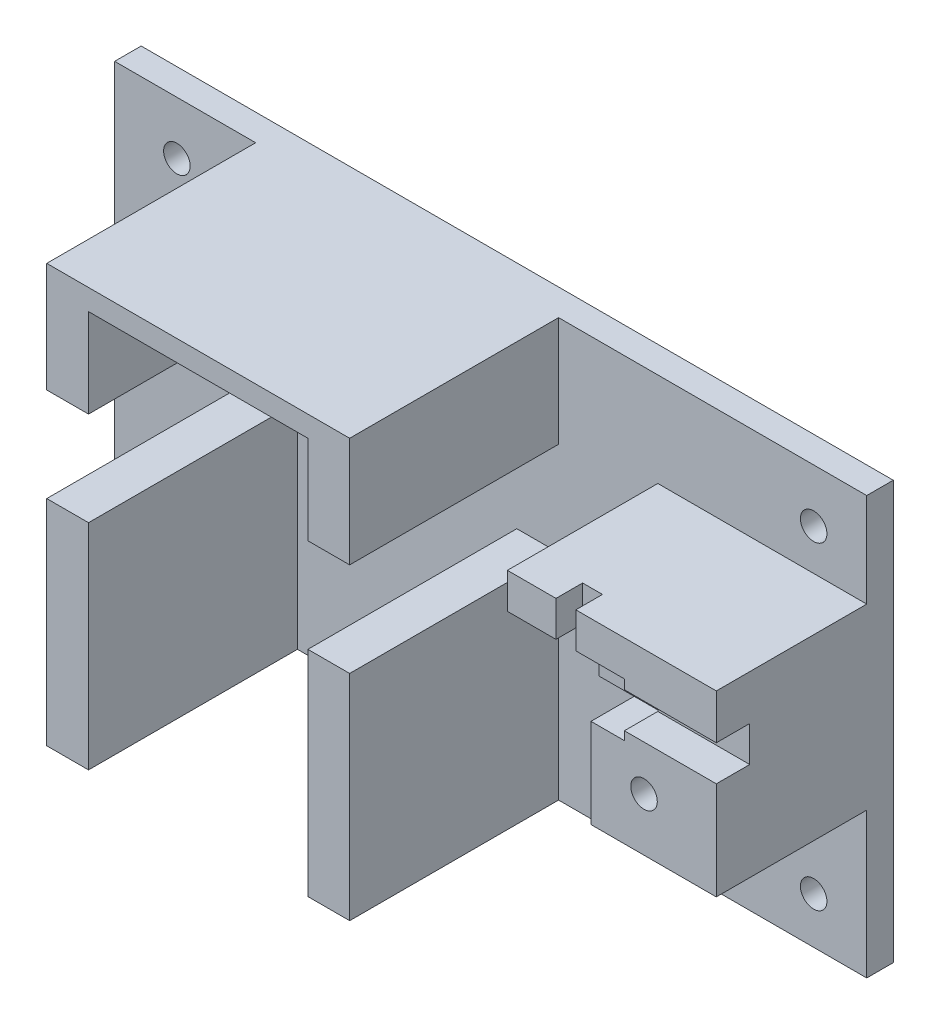
from build123d import *

# Parameters (mm, degrees)
SKETCH1_W            = 180
SKETCH1_H            = 100
BOSS_EXTRUDE1_DEPTH  = 6.35
SKETCH2_W            = 26.25
SKETCH2_H            = 5
BOSS_EXTRUDE3_DEPTH  = 50
SKETCH3_W            = 30
SKETCH3_H            = 30
BOSS_EXTRUDE4_DEPTH  = 25.65
BOSS_EXTRUDE5_DEPTH  = 10.35
SKETCH5_W            = 22
SKETCH5_H            = 8.5
BOSS_EXTRUDE6_DEPTH  = 2.35
SKETCH6_W            = 20
SKETCH6_H            = 8.5
BOSS_EXTRUDE7_DEPTH  = 29.625
SKETCH8_W            = 3.625
SKETCH8_H            = 8.5
SKETCH8_W_2          = 11.625
BOSS_EXTRUDE8_DEPTH  = 6.375
SKETCH9_W            = 8.375
SKETCH9_H            = 12.8
BOSS_EXTRUDE9_DEPTH  = 25.65
SKETCH10_R           = 3.175
CUT_EXTRUDE1_DEPTH   = 6.35
SKETCH11_W           = 30
SKETCH11_H           = 12.7
BOSS_EXTRUDE10_DEPTH = 36
SKETCH12_R           = 3.175
CUT_EXTRUDE2_DEPTH   = 10


with BuildPart() as part:
    # Sketch1 → Boss-Extrude1 (new body)
    with BuildSketch(Plane.XY):
        with Locations((90, 50)):
            Rectangle(SKETCH1_W, SKETCH1_H)
    extrude(amount=BOSS_EXTRUDE1_DEPTH)

    # Sketch2 → Boss-Extrude3 (add)
    with BuildSketch(Plane.XY.offset(6.35)):
        Polygon((43.75, 95), (43.75, 100), (33.75, 100), (33.75, 73.75), (43.75, 73.75), align=None)
        with Locations((56.875, 97.5)):
            Rectangle(SKETCH2_W, SKETCH2_H)
        with Locations((83.125, 97.5)):
            Rectangle(SKETCH2_W, SKETCH2_H)
        Polygon((106.25, 100), (96.25, 100), (96.25, 95), (96.25, 73.75), (106.25, 73.75), align=None)
        Polygon((33.75, 0), (43.75, 0), (43.75, 5), (43.75, 51.25), (33.75, 51.25), align=None)
        Polygon((96.25, 5), (96.25, 0), (106.25, 0), (106.25, 51.25), (96.25, 51.25), align=None)
    extrude(amount=BOSS_EXTRUDE3_DEPTH)

    # Sketch3 → Boss-Extrude4 (add)
    with BuildSketch(Plane.XY.offset(6.35)):
        with Locations((165, 62.5)):
            Rectangle(SKETCH3_W, SKETCH3_H)
    extrude(amount=BOSS_EXTRUDE4_DEPTH)

    # Sketch4 → Boss-Extrude5 (add)
    with BuildSketch(Plane.XY.offset(32)):
        Polygon((150, 77.5), (150, 69), (158, 69), (158, 66.75), (180, 66.75), (180, 77.5), align=None)
        Polygon((158, 56.2), (150, 56.2), (150, 47.5), (180, 47.5), (180, 58.25), (158, 58.25), align=None)
    extrude(amount=BOSS_EXTRUDE5_DEPTH)

    # Sketch5 → Boss-Extrude6 (add)
    with BuildSketch(Plane.XY.offset(32)):
        with Locations((169, 62.5)):
            Rectangle(SKETCH5_W, SKETCH5_H)
    extrude(amount=BOSS_EXTRUDE6_DEPTH)

    # Sketch6 → Boss-Extrude7 (add)
    with BuildSketch(Plane.XY.offset(6.35)):
        with Locations((140, 73.25)):
            Rectangle(SKETCH6_W, SKETCH6_H)
    extrude(amount=BOSS_EXTRUDE7_DEPTH)

    # Sketch8 → Boss-Extrude8 (add)
    with BuildSketch(Plane.XY.offset(35.975)):
        with Locations((148.1875, 73.25)):
            Rectangle(SKETCH8_W, SKETCH8_H)
        with Locations((135.8125, 73.25)):
            Rectangle(SKETCH8_W_2, SKETCH8_H)
    extrude(amount=BOSS_EXTRUDE8_DEPTH)

    # Sketch9 → Boss-Extrude9 (add)
    with BuildSketch(Plane.XY.offset(6.35)):
        with Locations((145.8125, 62.6)):
            Rectangle(SKETCH9_W, SKETCH9_H)
    extrude(amount=BOSS_EXTRUDE9_DEPTH)

    # Sketch10 → Cut-Extrude1 (cut)
    with BuildSketch(Plane.XY.offset(6.35)):
        with Locations((14.9, 87.3)):
            Circle(SKETCH10_R)
        with Locations((167.3, 87.3)):
            Circle(SKETCH10_R)
        with Locations((167.3, 11.1)):
            Circle(SKETCH10_R)
        with Locations((14.9, 11.1)):
            Circle(SKETCH10_R)
    extrude(amount=-CUT_EXTRUDE1_DEPTH, mode=Mode.SUBTRACT)

    # Sketch11 → Boss-Extrude10 (add)
    with BuildSketch(Plane.XY.offset(6.35)):
        with Locations((165, 41.15)):
            Rectangle(SKETCH11_W, SKETCH11_H)
    extrude(amount=BOSS_EXTRUDE10_DEPTH)

    # Sketch12 → Cut-Extrude2 (cut)
    with BuildSketch(Plane.XY.offset(42.35)):
        with Locations((162.7, 47.5)):
            Circle(SKETCH12_R)
    extrude(amount=-CUT_EXTRUDE2_DEPTH, mode=Mode.SUBTRACT)


solid = part.part
